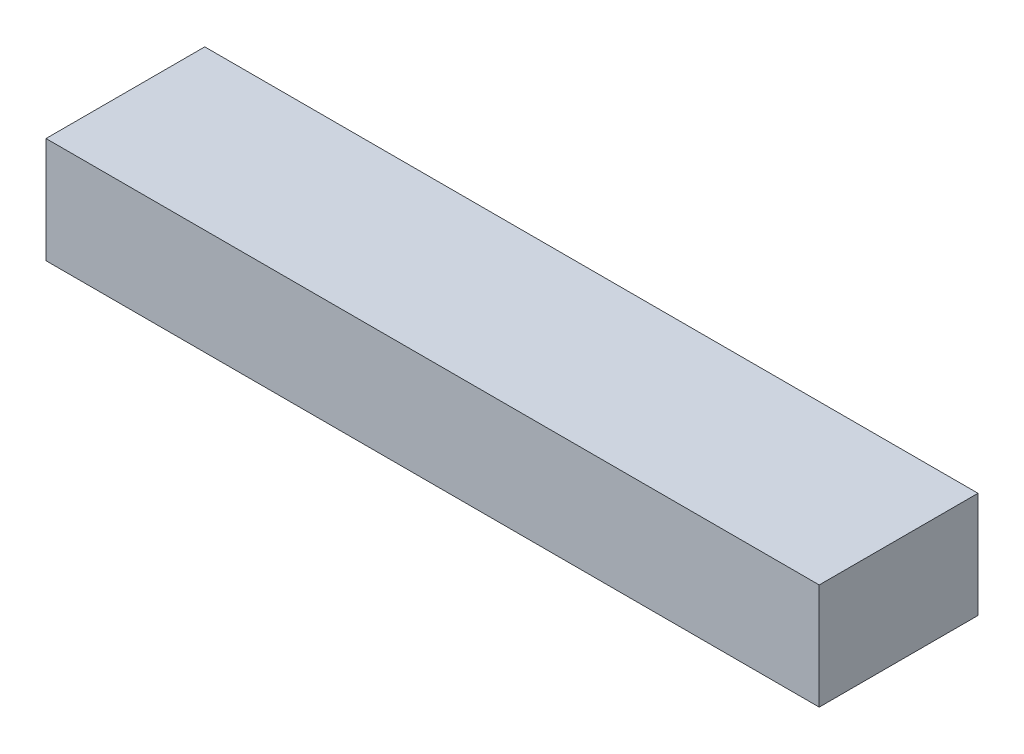
from build123d import *

# Parameters (mm, degrees)
SKETCH_1_W      = 73.05
SKETCH_1_H      = 15
EXTRUDE_1_DEPTH = 10


with BuildPart() as part:
    # 草图1 → 凸台-拉伸1 (new body)
    with BuildSketch(Plane(origin=(0, 0, 0), x_dir=(1, 0, 0), z_dir=(0, 1, 0))):
        with Locations((2.317153007, 31.662945232)):
            Rectangle(SKETCH_1_W, SKETCH_1_H)
    extrude(amount=EXTRUDE_1_DEPTH)


solid = part.part
